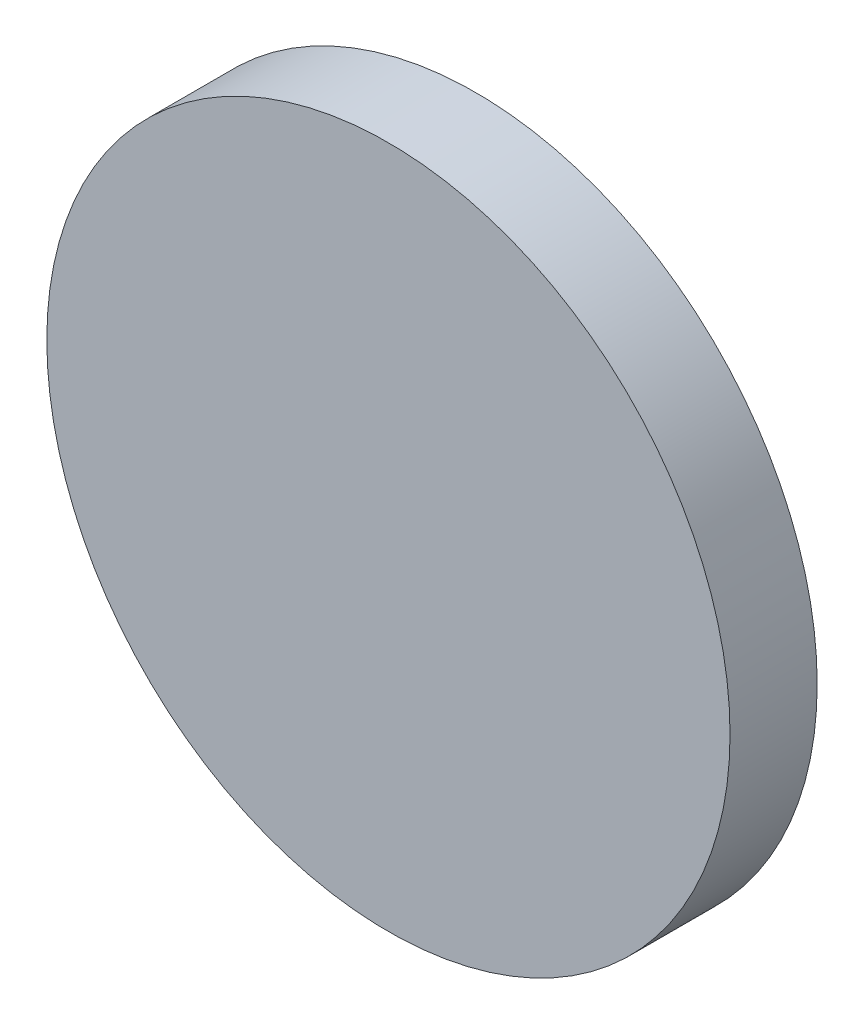
from build123d import *

# Parameters (mm, degrees)
SKETCH1_R           = 12.446
BOSS_EXTRUDE1_DEPTH = 3.175


with BuildPart() as part:
    # Sketch1 → Boss-Extrude1 (new body)
    with BuildSketch(Plane.XY):
        Circle(SKETCH1_R)
    extrude(amount=BOSS_EXTRUDE1_DEPTH)


solid = part.part
